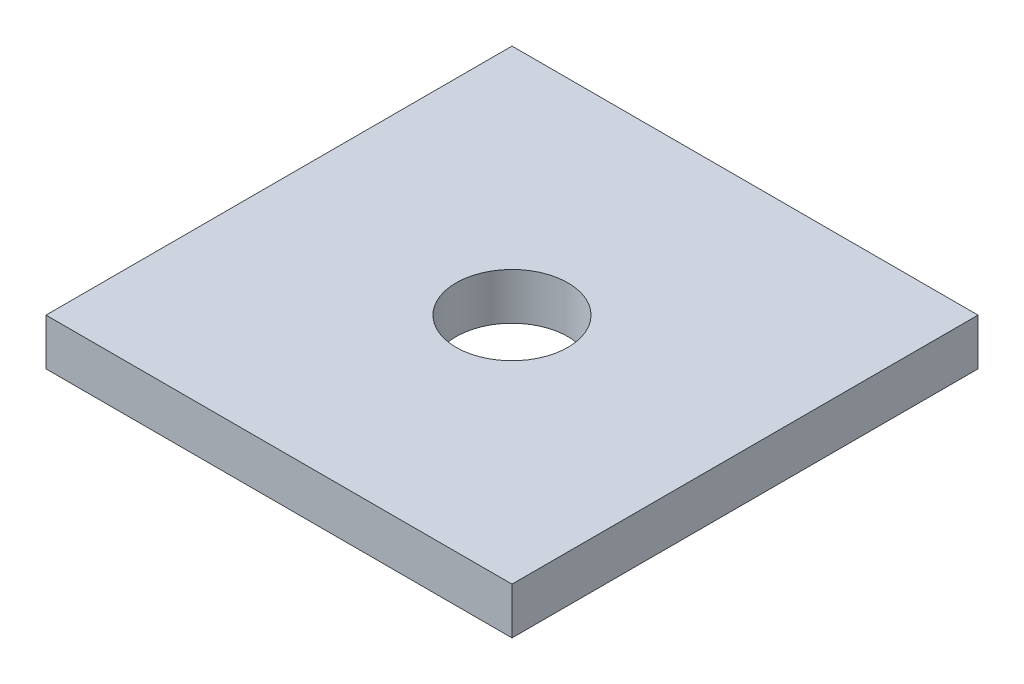
from build123d import *

# Parameters (mm, degrees)
SKETCH_1_W      = 50
SKETCH_1_H      = 50
SKETCH_1_R      = 6
EXTRUDE_1_DEPTH = 5


with BuildPart() as part:
    # Эскиз1 → Бобышка-Вытянуть1 (new body)
    with BuildSketch(Plane(origin=(0, 0, 0), x_dir=(1, 0, 0), z_dir=(0, 1, 0))):
        with Locations((25, 25)):
            Rectangle(SKETCH_1_W, SKETCH_1_H)
        with Locations((25, 25)):
            Circle(SKETCH_1_R, mode=Mode.SUBTRACT)
    extrude(amount=EXTRUDE_1_DEPTH)


solid = part.part
